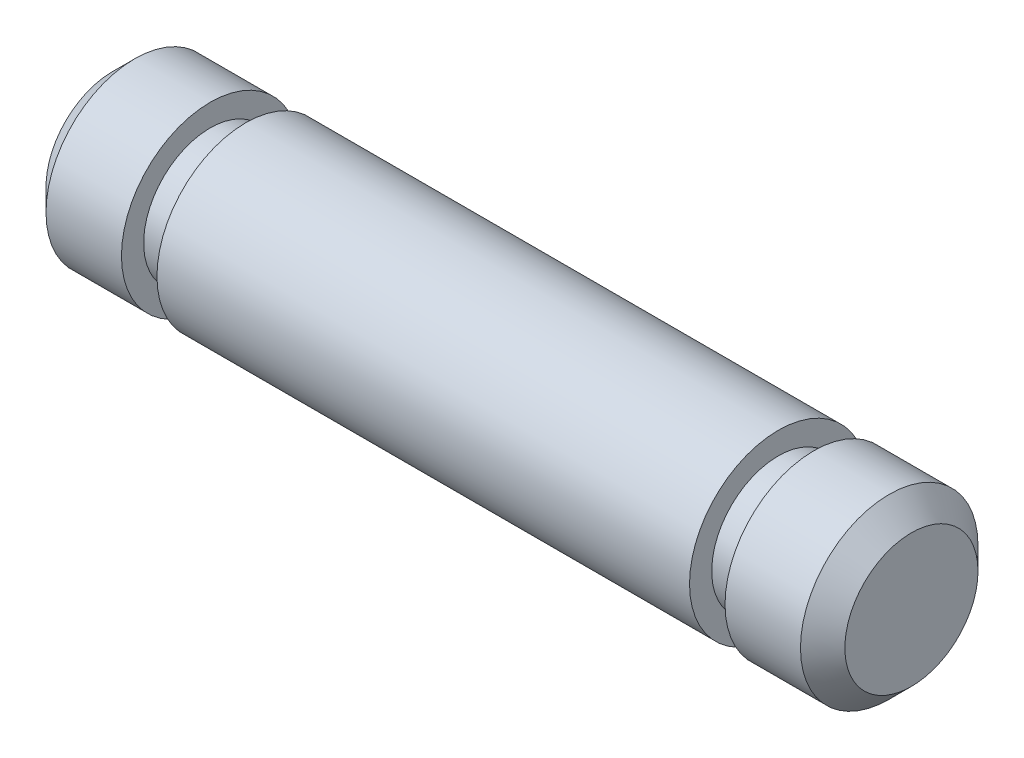
from build123d import *

# Parameters (mm, degrees)
SKETCH1_R           = 2
BOSS_EXTRUDE1_DEPTH = 9
CHAMFER1_SIZE       = 0.5
CUT_EXTRUDE1_START  = -3
SKETCH2_R           = 2
SKETCH2_R_2         = 1.5
CUT_EXTRUDE1_DEPTH  = 0.8


with BuildPart() as part:
    # Sketch1 → Boss-Extrude1 (new body, symmetric)
    with BuildSketch(Plane(origin=(0, 0, 0), x_dir=(0, 0, -1), z_dir=(1, 0, 0))):
        Circle(SKETCH1_R)
    extrude(amount=BOSS_EXTRUDE1_DEPTH, both=True)

    # Chamfer1
    chamfer1_edges = [part.edges().sort_by_distance(p)[0] for p in [
        (-9, 0, 2),
        (9, 0, 2),
    ]]
    chamfer(chamfer1_edges, length=CHAMFER1_SIZE)

    # Sketch2 → Cut-Extrude1 (cut)
    with BuildSketch(Plane(origin=(9, 0, 0), x_dir=(0, 0, -1), z_dir=(1, 0, 0)).offset(CUT_EXTRUDE1_START)):
        Circle(SKETCH2_R)
        Circle(SKETCH2_R_2, mode=Mode.SUBTRACT)
    cut_extrude1 = extrude(amount=CUT_EXTRUDE1_DEPTH, mode=Mode.SUBTRACT)

    # Mirror1: Cut-Extrude1 across plane
    add(cut_extrude1.mirror(Plane(origin=(0, 0, 0), x_dir=(0, 0, 1), z_dir=(1, 0, 0))), mode=Mode.SUBTRACT)


solid = part.part
